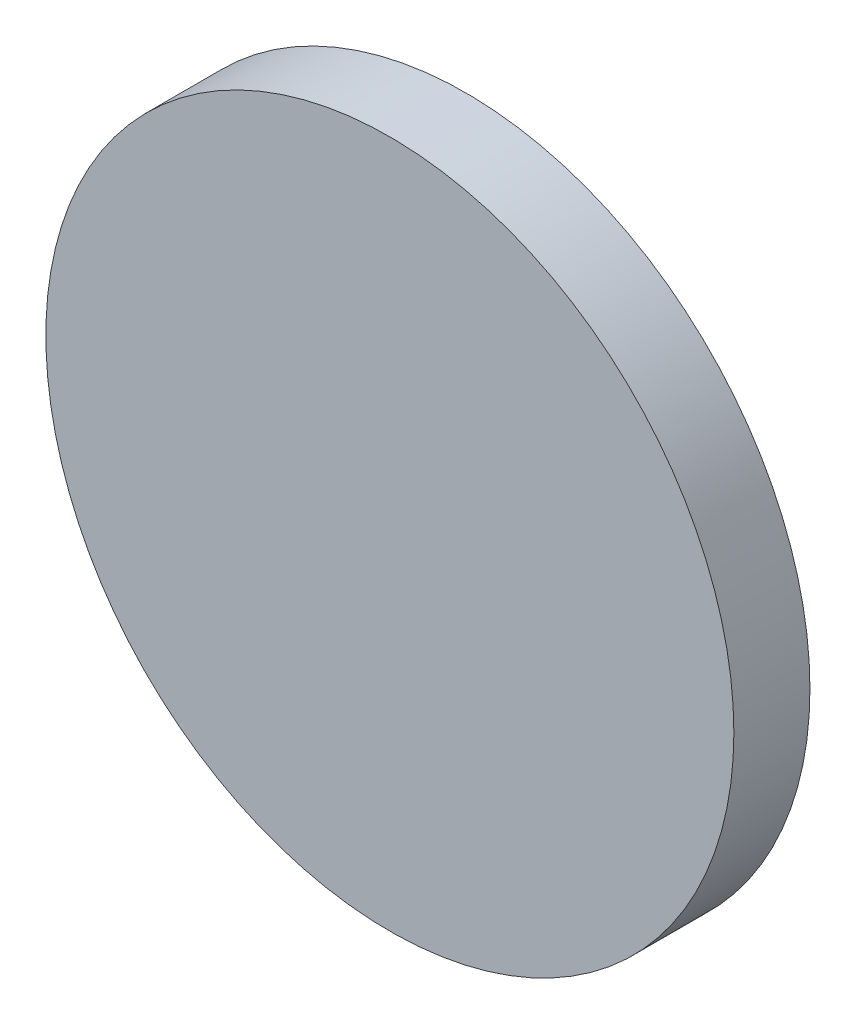
from build123d import *

# Parameters (mm, degrees)
SKETCH_2_R          = 2.6
CUT_EXTRUDE_1_DEPTH = 3


with BuildPart() as part:
    # 草图1 → 旋转1 (revolve)
    with BuildSketch(Plane(origin=(0, 0, 0), x_dir=(0, 0, -1), z_dir=(1, 0, 0))):
        Polygon((0, 10.4), (2.3, 10.4), (2.3, 4.4), (5.5, 4.4), (5.5, 0), (0, 0), align=None)
    revolve(axis=Axis((0, 0, 0), (0, 0, -1)))

    # 草图2 → 切除-拉伸1 (cut)
    with BuildSketch(Plane(origin=(0, 0, -5.5), x_dir=(-1, 0, 0), z_dir=(0, 0, -1))):
        Circle(SKETCH_2_R)
    extrude(amount=-CUT_EXTRUDE_1_DEPTH, mode=Mode.SUBTRACT)


solid = part.part
